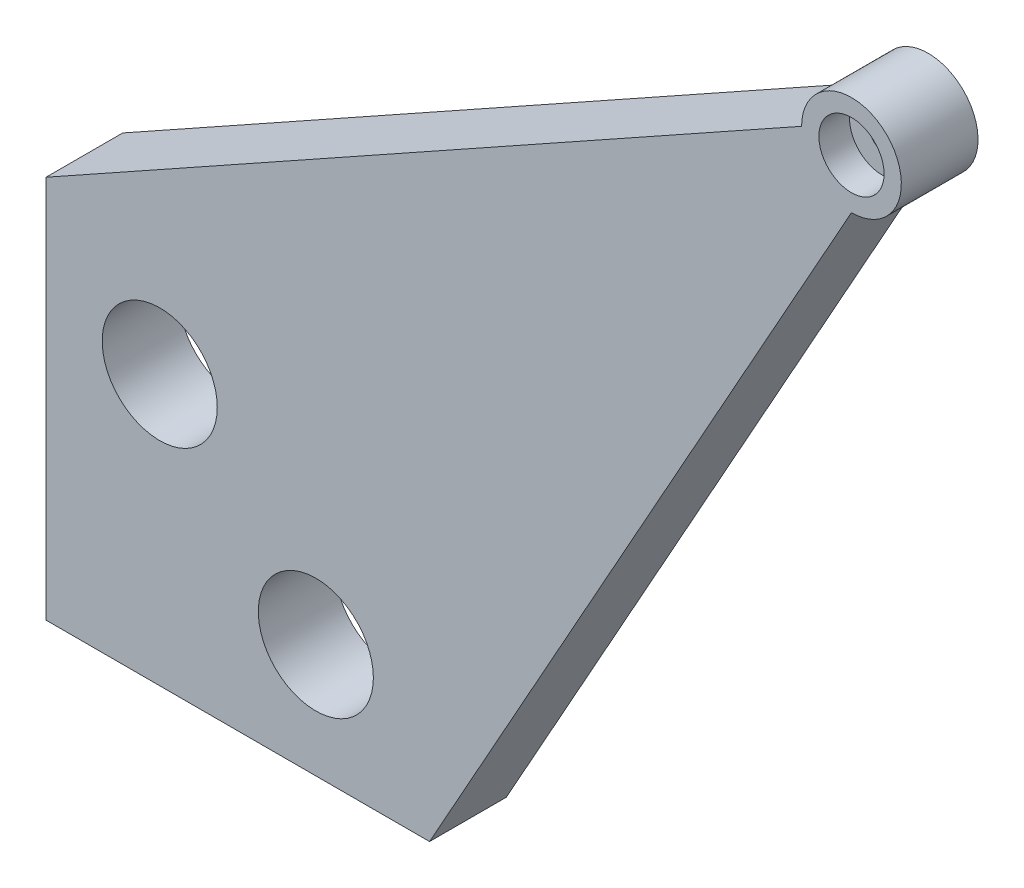
from build123d import *

# Parameters (mm, degrees)
RESSALTO_EXTRUS_O2_DEPTH = 5
ESBO_O4_R                = 4.25
CORTE_EXTRUS_O1_DEPTH    = 4
ESBO_O5_R                = 1.5
CORTE_EXTRUS_O2_DEPTH    = 7
ESBO_O6_R                = 7.5
CORTE_EXTRUS_O3_DEPTH    = 11


with BuildPart() as part:
    # Esboço3 → Ressalto-extrusão2 (new body, symmetric)
    with BuildSketch(Plane.XY):
        with BuildLine():
            Line((0, 50), (98.5, 105))
            ThreePointArc((98.5, 105), (109.596194078, 109.596194078), (105, 98.5))
            Line((105, 98.5), (50, 0))
            Line((50, 0), (0, 0))
            Line((0, 0), (0, 50))
        make_face()
    extrude(amount=RESSALTO_EXTRUS_O2_DEPTH, both=True)

    # Esboço4 → Corte-extrusão1 (cut)
    with BuildSketch(Plane.XY.offset(5)):
        with Locations((105, 105)):
            Circle(ESBO_O4_R)
    extrude(amount=-CORTE_EXTRUS_O1_DEPTH, mode=Mode.SUBTRACT)

    # Esboço5 → Corte-extrusão2 (cut, through all)
    with BuildSketch(Plane.XY.offset(1)):
        with Locations((105, 105)):
            Circle(ESBO_O5_R)
    extrude(amount=-CORTE_EXTRUS_O2_DEPTH, mode=Mode.SUBTRACT)

    # Esboço6 → Corte-extrusão3 (cut, through all)
    with BuildSketch(Plane.XY.offset(5)):
        with Locations((14.825558834, 35.174441166)):
            Circle(ESBO_O6_R)
        with Locations((35.174441166, 14.825558834)):
            Circle(ESBO_O6_R)
    extrude(amount=-CORTE_EXTRUS_O3_DEPTH, mode=Mode.SUBTRACT)


solid = part.part
